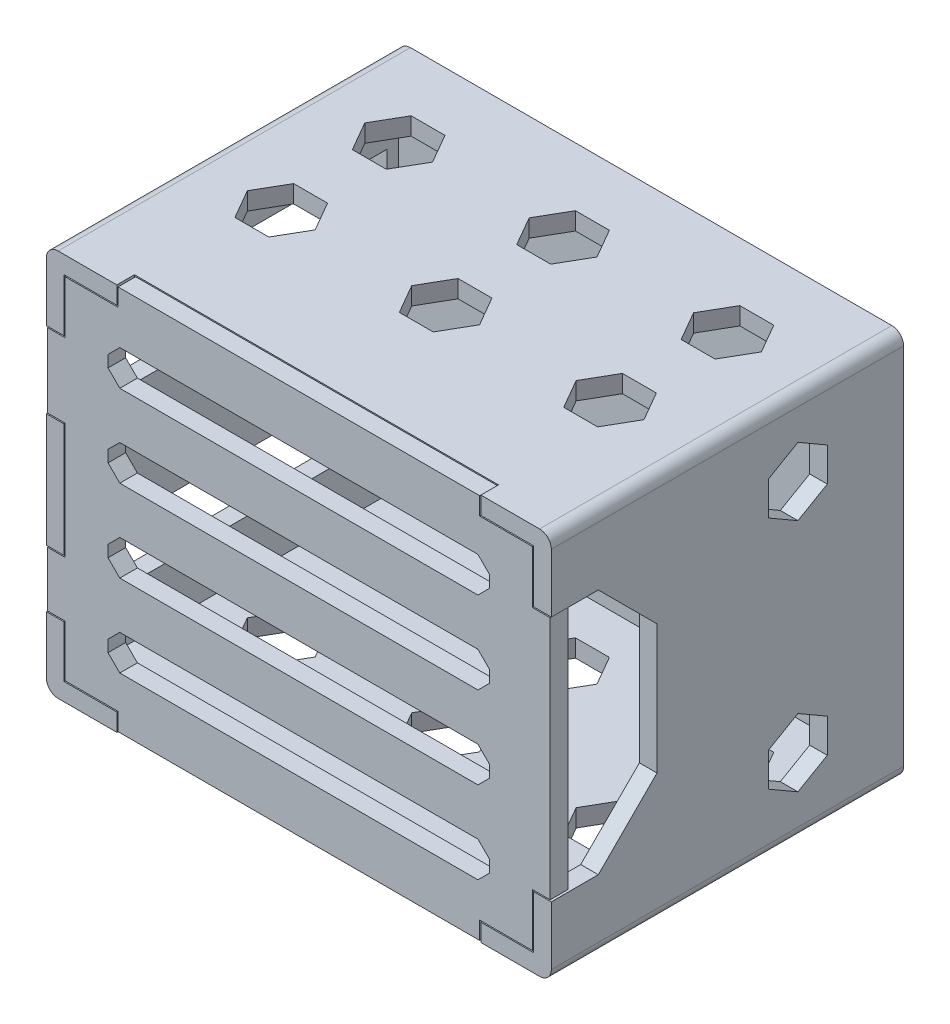
from build123d import *

# Parameters (mm, degrees)
SKETCH1_W           = 86
SKETCH1_H           = 66
SKETCH1_W_2         = 80
SKETCH1_H_2         = 60
BOSS_EXTRUDE1_DEPTH = 60
SKETCH1_2_W         = 80
SKETCH1_2_H         = 60
BOSS_EXTRUDE2_DEPTH = 3
CUT_EXTRUDE1_REACH  = 88
SKETCH2_W           = 55
SKETCH2_H           = 9.8
SKETCH2_H_2         = 13
CUT_EXTRUDE2_DEPTH  = 67
CUT_EXTRUDE3_REACH  = 88
SKETCH5_W           = 62
SKETCH5_H           = 3
SKETCH5_W_2         = 3
SKETCH5_H_2         = 42
CUT_EXTRUDE4_DEPTH  = 3
SKETCH6_W           = 2.8
SKETCH6_H           = 41.6
BOSS_EXTRUDE3_DEPTH = 3
SKETCH7_W           = 65
SKETCH7_H           = 6
CUT_EXTRUDE5_DEPTH  = 3
SKETCH8_W           = 3
SKETCH8_H           = 42
CUT_EXTRUDE6_DEPTH  = 15
CHAMFER1_SIZE       = 2
FILLET1_R           = 2
CHAMFER2_SIZE       = 10


with BuildPart() as part:
    # Sketch1 → Boss-Extrude1 (new body)
    with BuildSketch(Plane.XY):
        Rectangle(SKETCH1_W, SKETCH1_H)
        Rectangle(SKETCH1_W_2, SKETCH1_H_2, mode=Mode.SUBTRACT)
    extrude(amount=BOSS_EXTRUDE1_DEPTH)

    # Sketch1_2 → Boss-Extrude2 (add)
    with BuildSketch(Plane.XY):
        Rectangle(SKETCH1_2_W, SKETCH1_2_H)
    extrude(amount=BOSS_EXTRUDE2_DEPTH)

    # Sketch2 → Cut-Extrude1 (cut, up to next)
    with BuildSketch(Plane.ZY.offset(43), mode=Mode.PRIVATE) as cut_extrude1_sk1:
        with Locations((32.5, -16.3)):
            Rectangle(SKETCH2_W, SKETCH2_H)
    cut_extrude1_tool1 = extrude(cut_extrude1_sk1.sketch, amount=-CUT_EXTRUDE1_REACH, mode=Mode.PRIVATE) & part.part
    add(cut_extrude1_tool1.solids().sort_by_distance((-43, -16.3, 32.5))[0], mode=Mode.SUBTRACT)
    # Sketch2 → Cut-Extrude1 (cut, up to next)
    with BuildSketch(Plane.ZY.offset(43), mode=Mode.PRIVATE) as cut_extrude1_sk2:
        with Locations((32.5, 14.5)):
            Rectangle(SKETCH2_W, SKETCH2_H_2)
    cut_extrude1_tool2 = extrude(cut_extrude1_sk2.sketch, amount=-CUT_EXTRUDE1_REACH, mode=Mode.PRIVATE) & part.part
    add(cut_extrude1_tool2.solids().sort_by_distance((-43, 14.5, 32.5))[0], mode=Mode.SUBTRACT)

    # Sketch3 → Cut-Extrude2 (cut, through all)
    with BuildSketch(Plane.XZ.offset(33)):
        Polygon((-25.113248654, 40), (-30.886751346, 40), (-33.773502692, 35), (-30.886751346, 30), (-25.113248654, 30), (-22.226497308, 35), align=None)
        Polygon((2.886751346, 40), (-2.886751346, 40), (-5.773502692, 35), (-2.886751346, 30), (2.886751346, 30), (5.773502692, 35), align=None)
        Polygon((30.886751346, 40), (25.113248654, 40), (22.226497308, 35), (25.113248654, 30), (30.886751346, 30), (33.773502692, 35), align=None)
        Polygon((30.886751346, 20), (25.113248654, 20), (22.226497308, 15), (25.113248654, 10), (30.886751346, 10), (33.773502692, 15), align=None)
        Polygon((2.886751346, 20), (-2.886751346, 20), (-5.773502692, 15), (-2.886751346, 10), (2.886751346, 10), (5.773502692, 15), align=None)
        Polygon((-25.113248654, 20), (-30.886751346, 20), (-33.773502692, 15), (-30.886751346, 10), (-25.113248654, 10), (-22.226497308, 15), align=None)
    extrude(amount=-CUT_EXTRUDE2_DEPTH, mode=Mode.SUBTRACT)

    # Sketch4 → Cut-Extrude3 (cut, up to next)
    with BuildSketch(Plane(origin=(43, 0, 0), x_dir=(0, 0, -1), z_dir=(1, 0, 0)), mode=Mode.PRIVATE) as cut_extrude3_sk1:
        Polygon((-18, 25.773502692), (-23, 22.886751346), (-23, 17.113248654), (-18, 14.226497308), (-13, 17.113248654), (-13, 22.886751346), align=None)
    cut_extrude3_tool1 = extrude(cut_extrude3_sk1.sketch, amount=-CUT_EXTRUDE3_REACH, mode=Mode.PRIVATE) & part.part
    add(cut_extrude3_tool1.solids().sort_by_distance((43, 20, 18))[0], mode=Mode.SUBTRACT)
    # Sketch4 → Cut-Extrude3 (cut, up to next)
    with BuildSketch(Plane(origin=(43, 0, 0), x_dir=(0, 0, -1), z_dir=(1, 0, 0)), mode=Mode.PRIVATE) as cut_extrude3_sk2:
        Polygon((-18, -14.226497308), (-23, -17.113248654), (-23, -22.886751346), (-18, -25.773502692), (-13, -22.886751346), (-13, -17.113248654), align=None)
    cut_extrude3_tool2 = extrude(cut_extrude3_sk2.sketch, amount=-CUT_EXTRUDE3_REACH, mode=Mode.PRIVATE) & part.part
    add(cut_extrude3_tool2.solids().sort_by_distance((43, -20, 18))[0], mode=Mode.SUBTRACT)

    # Sketch5 → Cut-Extrude4 (cut)
    with BuildSketch(Plane.XY.offset(60)):
        with Locations((0, 31.5)):
            Rectangle(SKETCH5_W, SKETCH5_H)
        with Locations((0, -31.5)):
            Rectangle(SKETCH5_W, SKETCH5_H)
        with Locations((41.5, 0)):
            Rectangle(SKETCH5_W_2, SKETCH5_H_2)
    extrude(amount=-CUT_EXTRUDE4_DEPTH, mode=Mode.SUBTRACT)

    # Sketch8 → Cut-Extrude6 (cut)
    with BuildSketch(Plane.XY.offset(57)):
        with Locations((41.5, 0)):
            Rectangle(SKETCH8_W, SKETCH8_H)
    extrude(amount=-CUT_EXTRUDE6_DEPTH, mode=Mode.SUBTRACT)

    # Fillet1
    fillet1_edges = [part.edges().sort_by_distance(p)[0] for p in [
        (-43, -33, 30),
        (-43, 33, 30),
        (43, 33, 30),
        (43, -33, 30),
    ]]
    fillet(fillet1_edges, radius=FILLET1_R)

    # Chamfer2
    chamfer2_edges = [part.edges().sort_by_distance(p)[0] for p in [
        (41.5, 21, 42),
        (41.5, -21, 42),
    ]]
    chamfer(chamfer2_edges, length=CHAMFER2_SIZE)


with BuildPart() as body_2:
    # Sketch6 → Boss-Extrude3 (new body)
    with BuildSketch(Plane.XY.offset(57)):
        Polygon((40, -20.8), (40, 20.8), (39.8, 20.8), (39.8, 29.8), (30.8, 29.8), (30.8, 32.8), (-30.8, 32.8), (-30.8, 29.8), (-39.8, 29.8), (-39.8, 20.8), (-42.8, 20.8), (-42.8, 8.2), (-39.8, 8.2), (-39.8, -11.6), (-42.8, -11.6), (-42.8, -21), (-39.8, -21), (-39.8, -29.8), (-30.8, -29.8), (-30.8, -32.8), (30.8, -32.8), (30.8, -29.8), (39.8, -29.8), (39.8, -20.8), align=None)
        with Locations((41.4, 0)):
            Rectangle(SKETCH6_W, SKETCH6_H)
    extrude(amount=BOSS_EXTRUDE3_DEPTH)

    # Sketch7 → Cut-Extrude5 (cut)
    with BuildSketch(Plane.XY.offset(60)):
        with Locations((0, 21)):
            Rectangle(SKETCH7_W, SKETCH7_H)
        with Locations((0, 7)):
            Rectangle(SKETCH7_W, SKETCH7_H)
        with Locations((0, -7)):
            Rectangle(SKETCH7_W, SKETCH7_H)
        with Locations((0, -21)):
            Rectangle(SKETCH7_W, SKETCH7_H)
    extrude(amount=-CUT_EXTRUDE5_DEPTH, mode=Mode.SUBTRACT)

    # Chamfer1
    chamfer1_edges = [body_2.edges().sort_by_distance(p)[0] for p in [
        (-32.5, -10, 58.5),
        (-32.5, -4, 58.5),
        (32.5, -4, 58.5),
        (32.5, -10, 58.5),
        (-32.5, -24, 58.5),
        (-32.5, -18, 58.5),
        (32.5, -18, 58.5),
        (32.5, -24, 58.5),
        (-32.5, 18, 58.5),
        (-32.5, 24, 58.5),
        (32.5, 24, 58.5),
        (32.5, 18, 58.5),
        (-32.5, 4, 58.5),
        (-32.5, 10, 58.5),
        (32.5, 10, 58.5),
        (32.5, 4, 58.5),
    ]]
    chamfer(chamfer1_edges, length=CHAMFER1_SIZE)


solid = Compound([part.part, body_2.part])
